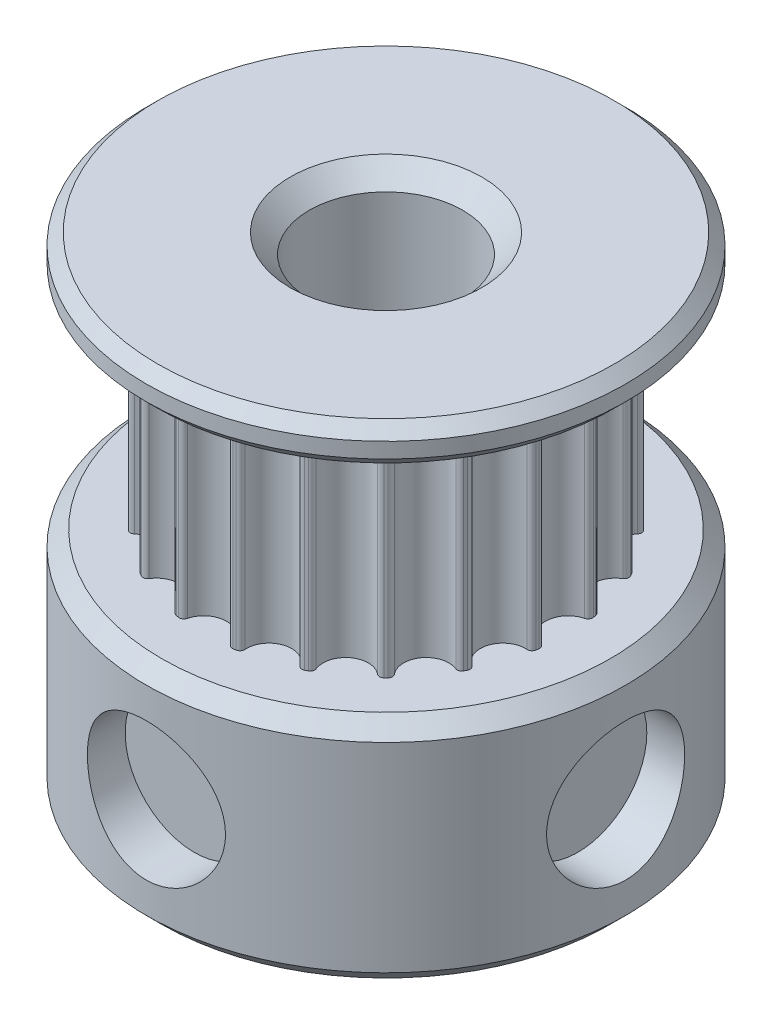
from build123d import *

# Parameters (mm, degrees)
BOSS_EXTRUDE1_DEPTH      = 7.239
SKETCH3_R                = 7.9375
BOSS_EXTRUDE2_DEPTH      = 7.62
M4_CLEARANCE_HOLE1_D     = 4.572
M4_CLEARANCE_HOLE1_DEPTH = 1.5875
M4_CLEARANCE_HOLE2_D     = 4.572
M4_CLEARANCE_HOLE2_DEPTH = 1.587491646
HOLE1_D                  = 5.08
HOLE1_DEPTH              = 16.129
CHAMFER1_SIZE            = 0.635
CHAMFER2_SIZE            = 0.508
FILLET1_R                = 0.152041167


with BuildPart() as part:
    # Sketch1 → Revolve1 (revolve)
    with BuildSketch(Plane(origin=(0, 0, 0), x_dir=(-1, 0, 0), z_dir=(0, 0, -1))):
        Polygon((-7.5565, 14.859), (0, 14.859), (0, 16.129), (-7.5565, 16.129), (-7.9375, 15.748), (-7.9375, 15.24), align=None)
    revolve(axis=Axis((0, 14.859, 0), (0, 1, 0)))

    # Sketch2 → Boss-Extrude1 (add)
    with BuildSketch(Plane.XZ.offset(-14.859)):
        with BuildLine():
            ThreePointArc((4.301108464, 4.22983714), (4.352221113, 4.177227266), (4.402690301, 4.123999801))
            ThreePointArc((4.402690301, 4.123999801), (4.273632273, 3.104975595), (5.282663008, 2.912821277))
            ThreePointArc((5.282663008, 2.912821277), (5.317689498, 2.848374036), (5.351929785, 2.783505672))
            add(Edge.make_bspline(
                [(5.397688791, 2.693698565), (5.382685881, 2.723761695), (5.367432879, 2.753697397), (5.351929785, 2.783505672)],
                knots=[0, 0, 0, 0, 1, 1, 1, 1], degree=3))
            ThreePointArc((5.397688791, 2.693698565), (5.430042465, 2.627868924), (5.461593324, 2.56165076))
            ThreePointArc((5.461593324, 2.56165076), (5.023956047, 1.632382273), (5.924222354, 1.137825011))
            ThreePointArc((5.924222354, 1.137825011), (5.937619233, 1.065708262), (5.950138253, 0.993433951))
            add(Edge.make_bspline(
                [(5.965905732, 0.893882007), (5.960927135, 0.927109897), (5.955671309, 0.960293879), (5.950138253, 0.993433951)],
                knots=[0, 0, 0, 0, 1, 1, 1, 1], degree=3))
            ThreePointArc((5.965905732, 0.893882007), (5.976333426, 0.821276462), (5.985877538, 0.748549495))
            ThreePointArc((5.985877538, 0.748549495), (5.2825, 0), (5.985877538, -0.748549495))
            ThreePointArc((5.985877538, -0.748549495), (5.976333426, -0.821276462), (5.965905732, -0.893882007))
            add(Edge.make_bspline(
                [(5.950138253, -0.993433951), (5.955671309, -0.960293879), (5.960927135, -0.927109897), (5.965905732, -0.893882007)],
                knots=[0, 0, 0, 0, 1, 1, 1, 1], degree=3))
            ThreePointArc((5.950138253, -0.993433951), (5.937619233, -1.065708262), (5.924222354, -1.137825011))
            ThreePointArc((5.924222354, -1.137825011), (5.023956047, -1.632382273), (5.461593324, -2.56165076))
            ThreePointArc((5.461593324, -2.56165076), (5.430042465, -2.627868924), (5.397688791, -2.693698565))
            add(Edge.make_bspline(
                [(5.351929785, -2.783505672), (5.367432879, -2.753697398), (5.382685881, -2.723761696), (5.397688791, -2.693698565)],
                knots=[0, 0, 0, 0, 1, 1, 1, 1], degree=3))
            ThreePointArc((5.351929785, -2.783505672), (5.317689498, -2.848374036), (5.282663008, -2.912821277))
            ThreePointArc((5.282663008, -2.912821277), (4.273632273, -3.104975595), (4.402690301, -4.123999801))
            ThreePointArc((4.402690301, -4.123999801), (4.352221113, -4.177227266), (4.301108464, -4.22983714))
            add(Edge.make_bspline(
                [(4.22983714, -4.301108464), (4.253792722, -4.27754983), (4.277549829, -4.253792723), (4.301108464, -4.22983714)],
                knots=[0, 0, 0, 0, 1, 1, 1, 1], degree=3))
            ThreePointArc((4.22983714, -4.301108464), (4.177227266, -4.352221113), (4.123999801, -4.402690301))
            ThreePointArc((4.123999801, -4.402690301), (3.104975595, -4.273632273), (2.912821277, -5.282663008))
            ThreePointArc((2.912821277, -5.282663008), (2.848374036, -5.317689498), (2.783505672, -5.351929785))
            add(Edge.make_bspline(
                [(2.693698565, -5.397688791), (2.723761695, -5.382685881), (2.753697397, -5.367432879), (2.783505672, -5.351929785)],
                knots=[0, 0, 0, 0, 1, 1, 1, 1], degree=3))
            ThreePointArc((2.693698565, -5.397688791), (2.627868924, -5.430042465), (2.56165076, -5.461593324))
            ThreePointArc((2.56165076, -5.461593324), (1.632382273, -5.023956047), (1.137825011, -5.924222354))
            ThreePointArc((1.137825011, -5.924222354), (1.065708262, -5.937619233), (0.993433951, -5.950138253))
            add(Edge.make_bspline(
                [(0.893882007, -5.965905732), (0.927109896, -5.960927135), (0.960293878, -5.955671309), (0.993433951, -5.950138253)],
                knots=[0, 0, 0, 0, 1, 1, 1, 1], degree=3))
            ThreePointArc((0.893882007, -5.965905732), (0.821276462, -5.976333426), (0.748549495, -5.985877538))
            ThreePointArc((0.748549495, -5.985877538), (0, -5.2825), (-0.748549495, -5.985877538))
            ThreePointArc((-0.748549495, -5.985877538), (-0.821276462, -5.976333426), (-0.893882007, -5.965905732))
            add(Edge.make_bspline(
                [(-0.993433951, -5.950138253), (-0.960293879, -5.955671309), (-0.927109897, -5.960927135), (-0.893882007, -5.965905732)],
                knots=[0, 0, 0, 0, 1, 1, 1, 1], degree=3))
            ThreePointArc((-0.993433951, -5.950138253), (-1.065708262, -5.937619233), (-1.137825011, -5.924222354))
            ThreePointArc((-1.137825011, -5.924222354), (-1.632382273, -5.023956047), (-2.56165076, -5.461593324))
            ThreePointArc((-2.56165076, -5.461593324), (-2.627868924, -5.430042465), (-2.693698565, -5.397688791))
            add(Edge.make_bspline(
                [(-2.783505672, -5.351929785), (-2.753697398, -5.367432879), (-2.723761696, -5.382685881), (-2.693698565, -5.397688791)],
                knots=[0, 0, 0, 0, 1, 1, 1, 1], degree=3))
            ThreePointArc((-2.783505672, -5.351929785), (-2.848374036, -5.317689498), (-2.912821277, -5.282663008))
            ThreePointArc((-2.912821277, -5.282663008), (-3.104975595, -4.273632273), (-4.123999801, -4.402690301))
            ThreePointArc((-4.123999801, -4.402690301), (-4.177227266, -4.352221113), (-4.22983714, -4.301108464))
            add(Edge.make_bspline(
                [(-4.301108464, -4.22983714), (-4.27754983, -4.253792722), (-4.253792723, -4.277549829), (-4.22983714, -4.301108464)],
                knots=[0, 0, 0, 0, 1, 1, 1, 1], degree=3))
            ThreePointArc((-4.301108464, -4.22983714), (-4.352221113, -4.177227266), (-4.402690301, -4.123999801))
            ThreePointArc((-4.402690301, -4.123999801), (-4.273632273, -3.104975595), (-5.282663008, -2.912821277))
            ThreePointArc((-5.282663008, -2.912821277), (-5.317689498, -2.848374036), (-5.351929785, -2.783505672))
            add(Edge.make_bspline(
                [(-5.397688791, -2.693698565), (-5.382685881, -2.723761695), (-5.367432879, -2.753697397), (-5.351929785, -2.783505672)],
                knots=[0, 0, 0, 0, 1, 1, 1, 1], degree=3))
            ThreePointArc((-5.397688791, -2.693698565), (-5.430042465, -2.627868924), (-5.461593324, -2.56165076))
            ThreePointArc((-5.461593324, -2.56165076), (-5.023956047, -1.632382273), (-5.924222354, -1.137825011))
            ThreePointArc((-5.924222354, -1.137825011), (-5.937619233, -1.065708262), (-5.950138253, -0.993433951))
            add(Edge.make_bspline(
                [(-5.965905732, -0.893882007), (-5.960927135, -0.927109896), (-5.955671309, -0.960293878), (-5.950138253, -0.993433951)],
                knots=[0, 0, 0, 0, 1, 1, 1, 1], degree=3))
            ThreePointArc((-5.965905732, -0.893882007), (-5.976333426, -0.821276462), (-5.985877538, -0.748549495))
            ThreePointArc((-5.985877538, -0.748549495), (-5.2825, 0), (-5.985877538, 0.748549495))
            ThreePointArc((-5.985877538, 0.748549495), (-5.976333426, 0.821276462), (-5.965905732, 0.893882007))
            add(Edge.make_bspline(
                [(-5.950138253, 0.993433951), (-5.955671309, 0.960293879), (-5.960927135, 0.927109897), (-5.965905732, 0.893882007)],
                knots=[0, 0, 0, 0, 1, 1, 1, 1], degree=3))
            ThreePointArc((-5.950138253, 0.993433951), (-5.937619233, 1.065708262), (-5.924222354, 1.137825011))
            ThreePointArc((-5.924222354, 1.137825011), (-5.023956047, 1.632382273), (-5.461593324, 2.56165076))
            ThreePointArc((-5.461593324, 2.56165076), (-5.430042465, 2.627868924), (-5.397688791, 2.693698565))
            add(Edge.make_bspline(
                [(-5.351929785, 2.783505672), (-5.367432879, 2.753697398), (-5.382685881, 2.723761696), (-5.397688791, 2.693698565)],
                knots=[0, 0, 0, 0, 1, 1, 1, 1], degree=3))
            ThreePointArc((-5.351929785, 2.783505672), (-5.317689498, 2.848374036), (-5.282663008, 2.912821277))
            ThreePointArc((-5.282663008, 2.912821277), (-4.273632273, 3.104975595), (-4.402690301, 4.123999801))
            ThreePointArc((-4.402690301, 4.123999801), (-4.352221113, 4.177227266), (-4.301108464, 4.22983714))
            add(Edge.make_bspline(
                [(-4.22983714, 4.301108464), (-4.253792722, 4.27754983), (-4.277549829, 4.253792723), (-4.301108464, 4.22983714)],
                knots=[0, 0, 0, 0, 1, 1, 1, 1], degree=3))
            ThreePointArc((-4.22983714, 4.301108464), (-4.177227266, 4.352221113), (-4.123999801, 4.402690301))
            ThreePointArc((-4.123999801, 4.402690301), (-3.104975595, 4.273632273), (-2.912821277, 5.282663008))
            ThreePointArc((-2.912821277, 5.282663008), (-2.848374036, 5.317689498), (-2.783505672, 5.351929785))
            add(Edge.make_bspline(
                [(-2.693698565, 5.397688791), (-2.723761695, 5.382685881), (-2.753697397, 5.367432879), (-2.783505672, 5.351929785)],
                knots=[0, 0, 0, 0, 1, 1, 1, 1], degree=3))
            ThreePointArc((-2.693698565, 5.397688791), (-2.627868924, 5.430042465), (-2.56165076, 5.461593324))
            ThreePointArc((-2.56165076, 5.461593324), (-1.632382273, 5.023956047), (-1.137825011, 5.924222354))
            ThreePointArc((-1.137825011, 5.924222354), (-1.065708262, 5.937619233), (-0.993433951, 5.950138253))
            add(Edge.make_bspline(
                [(-0.893882007, 5.965905732), (-0.927109896, 5.960927135), (-0.960293878, 5.955671309), (-0.993433951, 5.950138253)],
                knots=[0, 0, 0, 0, 1, 1, 1, 1], degree=3))
            ThreePointArc((-0.893882007, 5.965905732), (-0.821276462, 5.976333426), (-0.748549495, 5.985877538))
            ThreePointArc((-0.748549495, 5.985877538), (0, 5.2825), (0.748549495, 5.985877538))
            ThreePointArc((0.748549495, 5.985877538), (0.821276462, 5.976333426), (0.893882007, 5.965905732))
            add(Edge.make_bspline(
                [(0.993433951, 5.950138253), (0.960293879, 5.955671309), (0.927109897, 5.960927135), (0.893882007, 5.965905732)],
                knots=[0, 0, 0, 0, 1, 1, 1, 1], degree=3))
            ThreePointArc((0.993433951, 5.950138253), (1.065708262, 5.937619233), (1.137825011, 5.924222354))
            ThreePointArc((1.137825011, 5.924222354), (1.632382273, 5.023956047), (2.56165076, 5.461593324))
            ThreePointArc((2.56165076, 5.461593324), (2.627868924, 5.430042465), (2.693698565, 5.397688791))
            add(Edge.make_bspline(
                [(2.783505672, 5.351929785), (2.753697398, 5.367432879), (2.723761696, 5.382685881), (2.693698565, 5.397688791)],
                knots=[0, 0, 0, 0, 1, 1, 1, 1], degree=3))
            ThreePointArc((2.783505672, 5.351929785), (2.848374036, 5.317689498), (2.912821277, 5.282663008))
            ThreePointArc((2.912821277, 5.282663008), (3.104975595, 4.273632273), (4.123999801, 4.402690301))
            ThreePointArc((4.123999801, 4.402690301), (4.177227266, 4.352221113), (4.22983714, 4.301108464))
            add(Edge.make_bspline(
                [(4.301108464, 4.22983714), (4.27754983, 4.253792722), (4.253792723, 4.277549829), (4.22983714, 4.301108464)],
                knots=[0, 0, 0, 0, 1, 1, 1, 1], degree=3))
        make_face()
    extrude(amount=BOSS_EXTRUDE1_DEPTH)

    # Sketch3 → Boss-Extrude2 (add)
    with BuildSketch(Plane(origin=(0, 7.62, 0), x_dir=(1, 0, 0), z_dir=(0, 1, 0))):
        Circle(SKETCH3_R)
    extrude(amount=-BOSS_EXTRUDE2_DEPTH)

    # M4 Clearance Hole1
    with Locations(Plane(origin=(7.9375, 3.81, 0), x_dir=(0, 0, 1), z_dir=(1, 0, 0))):
        with Locations((0, 0)):
            Hole(M4_CLEARANCE_HOLE1_D / 2, depth=M4_CLEARANCE_HOLE1_DEPTH)

    # M4 Clearance Hole2
    with Locations(Plane(origin=(0, 3.81, 7.9375), x_dir=(1, 0, 0), z_dir=(0, 0, 1))):
        with Locations((0, 0)):
            Hole(M4_CLEARANCE_HOLE2_D / 2, depth=M4_CLEARANCE_HOLE2_DEPTH)

    # Hole1
    with Locations(Plane(origin=(0, 0, 0), x_dir=(-1, 0, 0), z_dir=(0, -1, 0))):
        with Locations((0, 0)):
            Hole(HOLE1_D / 2, depth=HOLE1_DEPTH)

    # Chamfer1
    chamfer1_edges = [part.edges().sort_by_distance(p)[0] for p in [
        (-2.54, 0, 0),
        (-2.54, 16.129, 0),
    ]]
    chamfer(chamfer1_edges, length=CHAMFER1_SIZE)

    # Chamfer2
    chamfer2_edges = [part.edges().sort_by_distance(p)[0] for p in [
        (-7.9375, 0, 0),
        (-7.9375, 7.62, 0),
    ]]
    chamfer(chamfer2_edges, length=CHAMFER2_SIZE)

    # Fillet1
    fillet1_edges = [part.edges().sort_by_distance(p)[0] for p in [
        (4.123999801, 11.2395, -4.402690301),
        (-2.912821277, 11.2395, -5.282663008),
        (5.461593324, 11.2395, 2.56165076),
        (5.282663008, 11.2395, 2.912821277),
        (0.748549495, 11.2395, -5.985877538),
        (4.402690301, 11.2395, 4.123999801),
        (5.924222354, 11.2395, -1.137825011),
        (4.123999801, 11.2395, 4.402690301),
        (-4.402690301, 11.2395, -4.123999801),
        (2.912821277, 11.2395, 5.282663008),
        (-1.137825011, 11.2395, -5.924222354),
        (2.56165076, 11.2395, 5.461593324),
        (2.56165076, 11.2395, -5.461593324),
        (1.137825011, 11.2395, 5.924222354),
        (5.282663008, 11.2395, -2.912821277),
        (0.748549495, 11.2395, 5.985877538),
        (5.985877538, 11.2395, 0.748549495),
        (-0.748549495, 11.2395, 5.985877538),
        (-5.282663008, 11.2395, -2.912821277),
        (-1.137825011, 11.2395, 5.924222354),
        (-4.123999801, 11.2395, -4.402690301),
        (-2.56165076, 11.2395, 5.461593324),
        (-2.56165076, 11.2395, -5.461593324),
        (-2.912821277, 11.2395, 5.282663008),
        (-0.748549495, 11.2395, -5.985877538),
        (-4.123999801, 11.2395, 4.402690301),
        (1.137825011, 11.2395, -5.924222354),
        (-4.402690301, 11.2395, 4.123999801),
        (2.912821277, 11.2395, -5.282663008),
        (-5.282663008, 11.2395, 2.912821277),
        (4.402690301, 11.2395, -4.123999801),
        (-5.461593324, 11.2395, 2.56165076),
        (5.461593324, 11.2395, -2.56165076),
        (-5.924222354, 11.2395, 1.137825011),
        (5.985877538, 11.2395, -0.748549495),
        (-5.985877538, 11.2395, 0.748549495),
        (5.924222354, 11.2395, 1.137825011),
        (-5.924222354, 11.2395, -1.137825011),
        (-5.461593324, 11.2395, -2.56165076),
        (-5.985877538, 11.2395, -0.748549495),
    ]]
    fillet(fillet1_edges, radius=FILLET1_R)


solid = part.part
